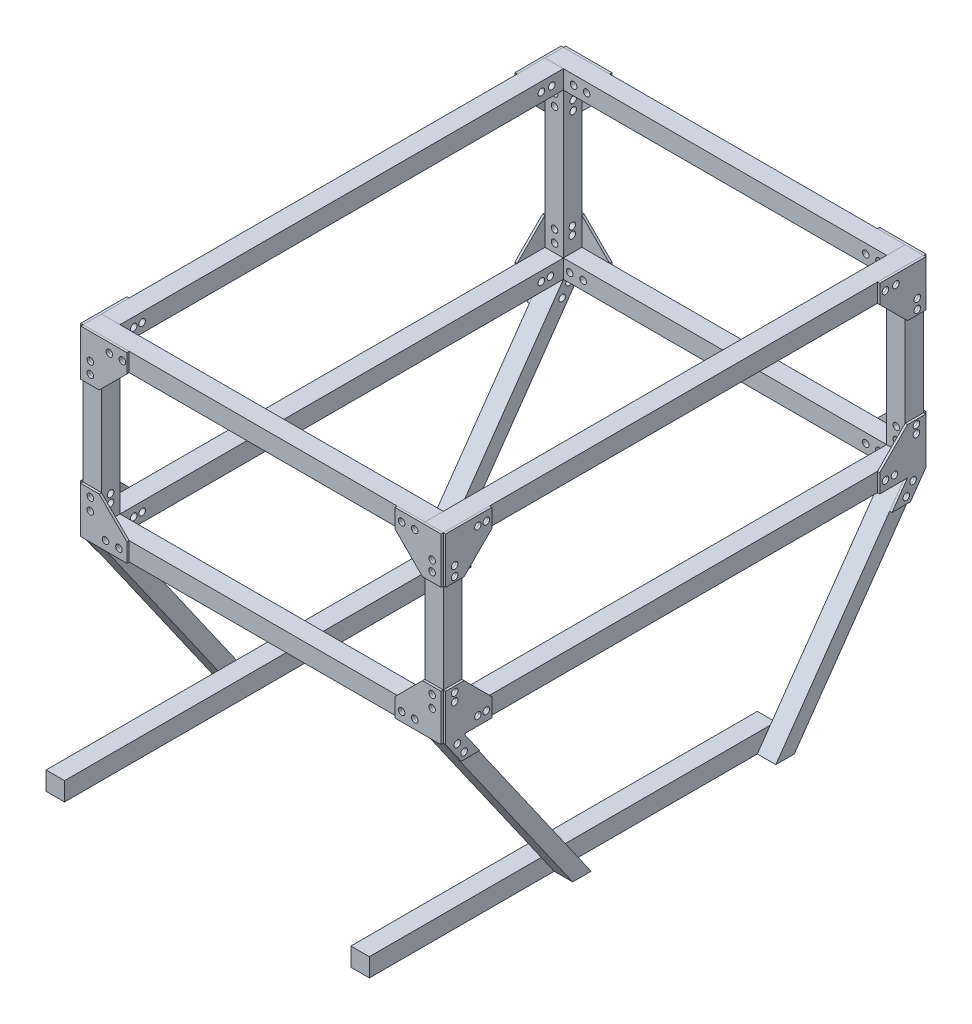
from build123d import *

# Parameters (mm, degrees)
SKETCH1_W                  = 12.7
SKETCH1_H                  = 12.7
BOSS_EXTRUDE1_DEPTH        = 304.8
SKETCH3_W                  = 12.7
SKETCH3_H                  = 12.7
BOSS_EXTRUDE2_DEPTH        = 222.25
BOSS_EXTRUDE2_DEPTH_BACK   = 12.7
BOSS_EXTRUDE2_2_DEPTH      = 222.25
BOSS_EXTRUDE2_2_DEPTH_BACK = 12.7
SKETCH5_W                  = 12.7
SKETCH5_H                  = 12.7
BOSS_EXTRUDE3_DEPTH        = 317.5
BOSS_EXTRUDE3_DEPTH_BACK   = 12.7
SKETCH6_W                  = 12.7
SKETCH6_H                  = 12.7
BOSS_EXTRUDE4_DEPTH        = 100
BOSS_EXTRUDE4_2_DEPTH      = 100
BOSS_EXTRUDE4_3_DEPTH      = 100
BOSS_EXTRUDE4_4_DEPTH      = 100
SKETCH8_W                  = 12.7
SKETCH8_H                  = 12.7
BOSS_EXTRUDE6_DEPTH        = 247.65
SKETCH9_W                  = 12.7
SKETCH9_H                  = 12.7
BOSS_EXTRUDE8_DEPTH        = 317.5
BOSS_EXTRUDE8_2_DEPTH      = 317.5
SKETCH10_W                 = 12.7
SKETCH10_H                 = 12.7
BOSS_EXTRUDE9_DEPTH        = 222.25
BOSS_EXTRUDE11_DEPTH       = 12.7
BOSS_EXTRUDE12_DEPTH       = 12.7
BOSS_EXTRUDE13_DEPTH       = 12.7
BOSS_EXTRUDE13_2_DEPTH     = 12.7
SKETCH15_W                 = 279.4
SKETCH15_H                 = 12.7
BOSS_EXTRUDE15_DEPTH       = 12.7
SKETCH16_W                 = 279.4
SKETCH16_H                 = 12.7
BOSS_EXTRUDE16_DEPTH       = 12.7
SKETCH17_R                 = 2.25
BOSS_EXTRUDE17_DEPTH       = 1.5875
BOSS_EXTRUDE17_2_DEPTH     = 1.5875
BOSS_EXTRUDE17_3_DEPTH     = 1.5875
BOSS_EXTRUDE17_4_DEPTH     = 1.5875
BOSS_EXTRUDE18_DEPTH       = 1.5875
BOSS_EXTRUDE18_2_DEPTH     = 1.5875
BOSS_EXTRUDE18_3_DEPTH     = 1.5875
BOSS_EXTRUDE18_4_DEPTH     = 1.5875
BOSS_EXTRUDE19_DEPTH       = 1.5875
BOSS_EXTRUDE19_2_DEPTH     = 1.5875
BOSS_EXTRUDE19_3_DEPTH     = 1.5875
BOSS_EXTRUDE19_4_DEPTH     = 1.5875
SKETCH20_R                 = 2.25
BOSS_EXTRUDE20_DEPTH       = 1.5875
BOSS_EXTRUDE20_2_DEPTH     = 1.5875
BOSS_EXTRUDE20_3_DEPTH     = 1.5875
BOSS_EXTRUDE20_4_DEPTH     = 1.5875
SKETCH17_4_R               = 2.25
CUT_EXTRUDE1_DEPTH         = 250.2375
SKETCH17_6_R               = 2.25
CUT_EXTRUDE4_DEPTH         = 250.2375
SKETCH17_7_R               = 2.25
CUT_EXTRUDE5_DEPTH         = 250.2375
SKETCH20_2_R               = 2.25
CUT_EXTRUDE6_DEPTH         = 369.326357353


with BuildPart() as part:
    # Sketch1 → Boss-Extrude1 (new body)
    with BuildSketch(Plane.XY):
        with Locations((6.35, 6.35)):
            Rectangle(SKETCH1_W, SKETCH1_H)
    extrude(amount=BOSS_EXTRUDE1_DEPTH)


with BuildPart() as body_2:
    # Sketch3 → Boss-Extrude2 (new body, two sides)
    with BuildSketch(Plane(origin=(12.7, 0, 0), x_dir=(0, 0, -1), z_dir=(1, 0, 0))) as boss_extrude2_sk:
        with Locations((6.35, 6.35)):
            Rectangle(SKETCH3_W, SKETCH3_H)
    extrude(amount=BOSS_EXTRUDE2_DEPTH)
    extrude(boss_extrude2_sk.sketch, amount=-BOSS_EXTRUDE2_DEPTH_BACK)


with BuildPart() as body_3:
    # Sketch3 → Boss-Extrude2 2 (new body, two sides)
    with BuildSketch(Plane(origin=(12.7, 0, 0), x_dir=(0, 0, -1), z_dir=(1, 0, 0))) as boss_extrude2_2_sk:
        with Locations((-311.15, 6.35)):
            Rectangle(SKETCH3_W, SKETCH3_H)
    extrude(amount=BOSS_EXTRUDE2_2_DEPTH)
    extrude(boss_extrude2_2_sk.sketch, amount=-BOSS_EXTRUDE2_2_DEPTH_BACK)


with BuildPart() as body_4:
    # Sketch5 → Boss-Extrude3 (new body, two sides)
    with BuildSketch(Plane(origin=(0, 0, 304.8), x_dir=(-1, 0, 0), z_dir=(0, 0, -1))) as boss_extrude3_sk:
        with Locations((-241.3, 6.35)):
            Rectangle(SKETCH5_W, SKETCH5_H)
    extrude(amount=BOSS_EXTRUDE3_DEPTH)
    extrude(boss_extrude3_sk.sketch, amount=-BOSS_EXTRUDE3_DEPTH_BACK)


with BuildPart() as body_5:
    # Sketch6 → Boss-Extrude4 (new body)
    with BuildSketch(Plane.XZ):
        with Locations((6.35, 311.15)):
            Rectangle(SKETCH6_W, SKETCH6_H)
    extrude(amount=BOSS_EXTRUDE4_DEPTH)


with BuildPart() as body_6:
    # Sketch6 → Boss-Extrude4 2 (new body)
    with BuildSketch(Plane.XZ):
        with Locations((241.3, 311.15)):
            Rectangle(SKETCH6_W, SKETCH6_H)
    extrude(amount=BOSS_EXTRUDE4_2_DEPTH)


with BuildPart() as body_7:
    # Sketch6 → Boss-Extrude4 3 (new body)
    with BuildSketch(Plane.XZ):
        with Locations((6.35, -6.35)):
            Rectangle(SKETCH6_W, SKETCH6_H)
    extrude(amount=BOSS_EXTRUDE4_3_DEPTH)


with BuildPart() as body_8:
    # Sketch6 → Boss-Extrude4 4 (new body)
    with BuildSketch(Plane.XZ):
        with Locations((241.3, -6.35)):
            Rectangle(SKETCH6_W, SKETCH6_H)
    extrude(amount=BOSS_EXTRUDE4_4_DEPTH)


with BuildPart() as body_9:
    # Sketch8 → Boss-Extrude6 (new body)
    with BuildSketch(Plane(origin=(247.65, 0, 0), x_dir=(0, 0, -1), z_dir=(1, 0, 0))):
        with Locations((-311.15, -106.35)):
            Rectangle(SKETCH8_W, SKETCH8_H)
    extrude(amount=-BOSS_EXTRUDE6_DEPTH)


with BuildPart() as body_10:
    # Sketch9 → Boss-Extrude8 (new body)
    with BuildSketch(Plane(origin=(0, 0, 304.8), x_dir=(-1, 0, 0), z_dir=(0, 0, -1))):
        with Locations((-241.3, -106.35)):
            Rectangle(SKETCH9_W, SKETCH9_H)
    extrude(amount=BOSS_EXTRUDE8_DEPTH)


with BuildPart() as body_11:
    # Sketch9 → Boss-Extrude8 2 (new body)
    with BuildSketch(Plane(origin=(0, 0, 304.8), x_dir=(-1, 0, 0), z_dir=(0, 0, -1))):
        with Locations((-6.35, -106.35)):
            Rectangle(SKETCH9_W, SKETCH9_H)
    extrude(amount=BOSS_EXTRUDE8_2_DEPTH)


with BuildPart() as body_12:
    # Sketch10 → Boss-Extrude9 (new body)
    with BuildSketch(Plane.ZY.offset(-234.95)):
        with Locations((-6.35, -106.35)):
            Rectangle(SKETCH10_W, SKETCH10_H)
    extrude(amount=BOSS_EXTRUDE9_DEPTH)


with BuildPart() as body_13:
    # Sketch12 → Boss-Extrude11 (new body)
    with BuildSketch(Plane.ZY):
        Polygon((-12.7, -112.7), (0, -112.7), (88.926357353, -239.7), (76.226357353, -239.7), align=None)
    extrude(amount=-BOSS_EXTRUDE11_DEPTH)


with BuildPart() as body_14:
    # Sketch13 → Boss-Extrude12 (new body)
    with BuildSketch(Plane.ZY):
        Polygon((317.5, -112.7), (304.8, -112.7), (215.873642647, -239.7), (228.573642647, -239.7), align=None)
    extrude(amount=-BOSS_EXTRUDE12_DEPTH)


with BuildPart() as body_15:
    # Sketch14 → Boss-Extrude13 (new body)
    with BuildSketch(Plane(origin=(247.65, 0, 0), x_dir=(0, 0, -1), z_dir=(1, 0, 0))):
        Polygon((-317.5, -112.7), (-228.573642647, -239.7), (-215.873642647, -239.7), (-304.8, -112.7), align=None)
    extrude(amount=-BOSS_EXTRUDE13_DEPTH)


with BuildPart() as body_16:
    # Sketch14 → Boss-Extrude13 2 (new body)
    with BuildSketch(Plane(origin=(247.65, 0, 0), x_dir=(0, 0, -1), z_dir=(1, 0, 0))):
        Polygon((-88.926357353, -239.7), (-76.226357353, -239.7), (12.7, -112.7), (0, -112.7), align=None)
    extrude(amount=-BOSS_EXTRUDE13_2_DEPTH)


with BuildPart() as body_17:
    # Sketch15 → Boss-Extrude15 (new body)
    with BuildSketch(Plane(origin=(12.7, 0, 0), x_dir=(0, 0, -1), z_dir=(1, 0, 0))):
        with Locations((-215.926357353, -233.35)):
            Rectangle(SKETCH15_W, SKETCH15_H)
    extrude(amount=BOSS_EXTRUDE15_DEPTH)


with BuildPart() as body_18:
    # Sketch16 → Boss-Extrude16 (new body)
    with BuildSketch(Plane.ZY.offset(-234.95)):
        with Locations((215.926357353, -233.35)):
            Rectangle(SKETCH16_W, SKETCH16_H)
    extrude(amount=BOSS_EXTRUDE16_DEPTH)


with BuildPart() as body_19:
    # Sketch17 → Boss-Extrude17 (new body)
    with BuildSketch(Plane.ZY):
        Polygon((-12.7, 12.7), (19.05, 12.7), (19.05, 0), (0, -19.05), (-12.7, -19.05), align=None)
        with Locations((-6.784745725, -15.720800994)):
            Circle(SKETCH17_R, mode=Mode.SUBTRACT)
        with Locations((-6.784745725, -9.184482746)):
            Circle(SKETCH17_R, mode=Mode.SUBTRACT)
        with Locations((15.120753266, 6.361355247)):
            Circle(SKETCH17_R, mode=Mode.SUBTRACT)
        with Locations((7.966134644, 6.361355247)):
            Circle(SKETCH17_R, mode=Mode.SUBTRACT)
    extrude(amount=BOSS_EXTRUDE17_DEPTH)


with BuildPart() as body_20:
    # Sketch17 → Boss-Extrude17 2 (new body)
    with BuildSketch(Plane.ZY):
        Polygon((317.5, 12.7), (285.75, 12.7), (285.75, 0), (304.8, -19.05), (317.5, -19.05), align=None)
        with Locations((289.5092956, 6.361355247)):
            Circle(SKETCH17_R, mode=Mode.SUBTRACT)
        with Locations((295.315666091, 6.361355247)):
            Circle(SKETCH17_R, mode=Mode.SUBTRACT)
        with Locations((311.256792347, -15.720800994)):
            Circle(SKETCH17_R, mode=Mode.SUBTRACT)
        with Locations((311.256792347, -9.184482746)):
            Circle(SKETCH17_R, mode=Mode.SUBTRACT)
    extrude(amount=BOSS_EXTRUDE17_2_DEPTH)


with BuildPart() as body_21:
    # Sketch17 → Boss-Extrude17 3 (new body)
    with BuildSketch(Plane.ZY):
        Polygon((-12.7, -112.7), (-12.7, -80.95), (0, -80.95), (19.05, -100), (19.05, -112.7), (0, -112.7), (10.671162882, -127.94), (-2.028837118, -127.94), align=None)
        with Locations((-3.838603571, -116.183590647)):
            Circle(SKETCH17_R, mode=Mode.SUBTRACT)
        with Locations((0.82993715, -123.403794366)):
            Circle(SKETCH17_R, mode=Mode.SUBTRACT)
        with Locations((-6.105589472, -84.025820636)):
            Circle(SKETCH17_R, mode=Mode.SUBTRACT)
        with Locations((-6.105589472, -89.426038711)):
            Circle(SKETCH17_R, mode=Mode.SUBTRACT)
        with Locations((15.120753266, -106.479113212)):
            Circle(SKETCH17_R, mode=Mode.SUBTRACT)
        with Locations((8.932434355, -106.479113212)):
            Circle(SKETCH17_R, mode=Mode.SUBTRACT)
    extrude(amount=BOSS_EXTRUDE17_3_DEPTH)


with BuildPart() as body_22:
    # Sketch17 → Boss-Extrude17 4 (new body)
    with BuildSketch(Plane.ZY):
        Polygon((317.5, -112.7), (317.5, -80.95), (304.8, -80.95), (285.75, -100), (285.75, -112.7), (304.8, -112.7), (294.128837118, -127.94), (306.828837118, -127.94), align=None)
        with Locations((311.256792347, -84.677899091)):
            Circle(SKETCH17_R, mode=Mode.SUBTRACT)
        with Locations((289.5092956, -106.479113212)):
            Circle(SKETCH17_R, mode=Mode.SUBTRACT)
        with Locations((295.315666091, -106.479113212)):
            Circle(SKETCH17_R, mode=Mode.SUBTRACT)
        with Locations((309.468904671, -116.183590647)):
            Circle(SKETCH17_R, mode=Mode.SUBTRACT)
        with Locations((304.8, -123.403794366)):
            Circle(SKETCH17_R, mode=Mode.SUBTRACT)
        with Locations((311.256792347, -90.324282695)):
            Circle(SKETCH17_R, mode=Mode.SUBTRACT)
    extrude(amount=BOSS_EXTRUDE17_4_DEPTH)


with BuildPart() as body_23:
    # Sketch18 → Boss-Extrude18 (new body)
    with BuildSketch(Plane.XY.offset(317.5)):
        Polygon((0, 12.7), (31.75, 12.7), (31.75, 0), (12.7, -19.05), (0, -19.05), align=None)
    extrude(amount=BOSS_EXTRUDE18_DEPTH)


with BuildPart() as body_24:
    # Sketch18 → Boss-Extrude18 2 (new body)
    with BuildSketch(Plane.XY.offset(317.5)):
        Polygon((247.65, 12.7), (247.65, -19.05), (234.95, -19.05), (215.9, 0), (215.9, 12.7), align=None)
    extrude(amount=BOSS_EXTRUDE18_2_DEPTH)


with BuildPart() as body_25:
    # Sketch18 → Boss-Extrude18 3 (new body)
    with BuildSketch(Plane.XY.offset(317.5)):
        Polygon((0, -112.7), (31.75, -112.7), (31.75, -100), (12.7, -80.95), (0, -80.95), align=None)
    extrude(amount=BOSS_EXTRUDE18_3_DEPTH)


with BuildPart() as body_26:
    # Sketch18 → Boss-Extrude18 4 (new body)
    with BuildSketch(Plane.XY.offset(317.5)):
        Polygon((247.65, -112.7), (247.65, -80.95), (234.95, -80.95), (215.9, -100), (215.9, -112.7), align=None)
    extrude(amount=BOSS_EXTRUDE18_4_DEPTH)


with BuildPart() as body_27:
    # Sketch19 → Boss-Extrude19 (new body)
    with BuildSketch(Plane(origin=(247.65, 0, 0), x_dir=(0, 0, -1), z_dir=(1, 0, 0))):
        Polygon((-317.5, 12.7), (-285.75, 12.7), (-285.75, 0), (-304.8, -19.05), (-317.5, -19.05), align=None)
    extrude(amount=BOSS_EXTRUDE19_DEPTH)


with BuildPart() as body_28:
    # Sketch19 → Boss-Extrude19 2 (new body)
    with BuildSketch(Plane(origin=(247.65, 0, 0), x_dir=(0, 0, -1), z_dir=(1, 0, 0))):
        Polygon((12.7, 12.7), (12.7, -19.05), (0, -19.05), (-19.05, 0), (-19.05, 12.7), align=None)
    extrude(amount=BOSS_EXTRUDE19_2_DEPTH)


with BuildPart() as body_29:
    # Sketch19 → Boss-Extrude19 3 (new body)
    with BuildSketch(Plane(origin=(247.65, 0, 0), x_dir=(0, 0, -1), z_dir=(1, 0, 0))):
        Polygon((-285.75, -112.7), (-285.75, -100), (-304.8, -80.95), (-317.5, -80.95), (-317.5, -112.7), (-306.828837118, -127.94), (-294.128837118, -127.94), (-304.8, -112.7), align=None)
    extrude(amount=BOSS_EXTRUDE19_3_DEPTH)


with BuildPart() as body_30:
    # Sketch19 → Boss-Extrude19 4 (new body)
    with BuildSketch(Plane(origin=(247.65, 0, 0), x_dir=(0, 0, -1), z_dir=(1, 0, 0))):
        Polygon((12.7, -112.7), (12.7, -80.95), (0, -80.95), (-19.05, -100), (-19.05, -112.7), (0, -112.7), (-10.671162882, -127.94), (2.028837118, -127.94), align=None)
    extrude(amount=BOSS_EXTRUDE19_4_DEPTH)


with BuildPart() as body_31:
    # Sketch20 → Boss-Extrude20 (new body)
    with BuildSketch(Plane(origin=(0, 0, -12.7), x_dir=(-1, 0, 0), z_dir=(0, 0, -1))):
        Polygon((-247.65, 12.7), (-215.9, 12.7), (-215.9, 0), (-234.95, -20.344786023), (-247.65, -19.05), align=None)
        with Locations((-220.629320264, 6.349721933)):
            Circle(SKETCH20_R, mode=Mode.SUBTRACT)
        with Locations((-229.622707283, 6.349721933)):
            Circle(SKETCH20_R, mode=Mode.SUBTRACT)
        with Locations((-241.543603879, -12.822038256)):
            Circle(SKETCH20_R, mode=Mode.SUBTRACT)
        with Locations((-241.543603879, -5.789410119)):
            Circle(SKETCH20_R, mode=Mode.SUBTRACT)
    extrude(amount=BOSS_EXTRUDE20_DEPTH)


with BuildPart() as body_32:
    # Sketch20 → Boss-Extrude20 2 (new body)
    with BuildSketch(Plane(origin=(0, 0, -12.7), x_dir=(-1, 0, 0), z_dir=(0, 0, -1))):
        Polygon((0, 12.7), (-31.75, 12.7), (-31.75, 0), (-12.7, -19.05), (0, -19.05), align=None)
        with Locations((-28.670930573, 6.349721933)):
            Circle(SKETCH20_R, mode=Mode.SUBTRACT)
        with Locations((-19.69681109, 6.349721933)):
            Circle(SKETCH20_R, mode=Mode.SUBTRACT)
        with Locations((-6.621386862, -4.890192644)):
            Circle(SKETCH20_R, mode=Mode.SUBTRACT)
        with Locations((-6.621386862, -12.822038256)):
            Circle(SKETCH20_R, mode=Mode.SUBTRACT)
    extrude(amount=BOSS_EXTRUDE20_2_DEPTH)


with BuildPart() as body_33:
    # Sketch20 → Boss-Extrude20 3 (new body)
    with BuildSketch(Plane(origin=(0, 0, -12.7), x_dir=(-1, 0, 0), z_dir=(0, 0, -1))):
        Polygon((-247.65, -112.7), (-215.9, -112.7), (-215.9, -100), (-234.95, -80.95), (-247.65, -80.95), align=None)
        with Locations((-241.543603879, -85.852301949)):
            Circle(SKETCH20_R, mode=Mode.SUBTRACT)
        with Locations((-241.543603879, -94.169193352)):
            Circle(SKETCH20_R, mode=Mode.SUBTRACT)
        with Locations((-229.622707283, -106.487386504)):
            Circle(SKETCH20_R, mode=Mode.SUBTRACT)
        with Locations((-220.629320264, -106.487386504)):
            Circle(SKETCH20_R, mode=Mode.SUBTRACT)
    extrude(amount=BOSS_EXTRUDE20_3_DEPTH)


with BuildPart() as body_34:
    # Sketch20 → Boss-Extrude20 4 (new body)
    with BuildSketch(Plane(origin=(0, 0, -12.7), x_dir=(-1, 0, 0), z_dir=(0, 0, -1))):
        Polygon((0, -112.7), (0, -80.95), (-12.7, -80.95), (-31.75, -100), (-31.75, -112.7), align=None)
        with Locations((-6.621386862, -85.852301949)):
            Circle(SKETCH20_R, mode=Mode.SUBTRACT)
        with Locations((-6.621386862, -94.169193352)):
            Circle(SKETCH20_R, mode=Mode.SUBTRACT)
        with Locations((-26.28770183, -106.487386504)):
            Circle(SKETCH20_R, mode=Mode.SUBTRACT)
        with Locations((-17.062185059, -106.487386504)):
            Circle(SKETCH20_R, mode=Mode.SUBTRACT)
    extrude(amount=BOSS_EXTRUDE20_4_DEPTH)


with BuildPart() as cut_extrude1_tool:
    # Sketch17_4 → Cut-Extrude1 (new body, through all)
    with BuildSketch(Plane.ZY):
        with Locations((15.120753266, 6.361355247)):
            Circle(SKETCH17_4_R)
        with Locations((7.966134644, 6.361355247)):
            Circle(SKETCH17_4_R)
        with Locations((-6.784745725, -9.184482746)):
            Circle(SKETCH17_4_R)
        with Locations((-6.784745725, -15.720800994)):
            Circle(SKETCH17_4_R)
    extrude(amount=-CUT_EXTRUDE1_DEPTH)


with BuildPart() as part_1:
    add(part.part)

    # Cut-Extrude1: cut by cut_extrude1_tool
    add(cut_extrude1_tool.part, mode=Mode.SUBTRACT)


with BuildPart() as body_4_1:
    add(body_4.part)

    # Cut-Extrude1: cut by cut_extrude1_tool
    add(cut_extrude1_tool.part, mode=Mode.SUBTRACT)


with BuildPart() as body_7_1:
    add(body_7.part)

    # Cut-Extrude1: cut by cut_extrude1_tool
    add(cut_extrude1_tool.part, mode=Mode.SUBTRACT)


with BuildPart() as body_8_1:
    add(body_8.part)

    # Cut-Extrude1: cut by cut_extrude1_tool
    add(cut_extrude1_tool.part, mode=Mode.SUBTRACT)


with BuildPart() as body_28_1:
    add(body_28.part)

    # Cut-Extrude1: cut by cut_extrude1_tool
    add(cut_extrude1_tool.part, mode=Mode.SUBTRACT)


with BuildPart() as cut_extrude4_tool:
    # Sketch17_6 → Cut-Extrude4 (new body, through all)
    with BuildSketch(Plane.ZY):
        with Locations((-6.105589472, -84.025820636)):
            Circle(SKETCH17_6_R)
        with Locations((-6.105589472, -89.426038711)):
            Circle(SKETCH17_6_R)
        with Locations((8.932434355, -106.479113212)):
            Circle(SKETCH17_6_R)
        with Locations((15.120753266, -106.479113212)):
            Circle(SKETCH17_6_R)
        with Locations((-3.838603571, -116.183590647)):
            Circle(SKETCH17_6_R)
        with Locations((0.82993715, -123.403794366)):
            Circle(SKETCH17_6_R)
    extrude(amount=-CUT_EXTRUDE4_DEPTH)


with BuildPart() as body_7_2:
    add(body_7_1.part)

    # Cut-Extrude4: cut by cut_extrude4_tool
    add(cut_extrude4_tool.part, mode=Mode.SUBTRACT)


with BuildPart() as body_8_2:
    add(body_8_1.part)

    # Cut-Extrude4: cut by cut_extrude4_tool
    add(cut_extrude4_tool.part, mode=Mode.SUBTRACT)


with BuildPart() as body_10_1:
    add(body_10.part)

    # Cut-Extrude4: cut by cut_extrude4_tool
    add(cut_extrude4_tool.part, mode=Mode.SUBTRACT)


with BuildPart() as body_11_1:
    add(body_11.part)

    # Cut-Extrude4: cut by cut_extrude4_tool
    add(cut_extrude4_tool.part, mode=Mode.SUBTRACT)


with BuildPart() as body_13_1:
    add(body_13.part)

    # Cut-Extrude4: cut by cut_extrude4_tool
    add(cut_extrude4_tool.part, mode=Mode.SUBTRACT)


with BuildPart() as body_16_1:
    add(body_16.part)

    # Cut-Extrude4: cut by cut_extrude4_tool
    add(cut_extrude4_tool.part, mode=Mode.SUBTRACT)


with BuildPart() as body_30_1:
    add(body_30.part)

    # Cut-Extrude4: cut by cut_extrude4_tool
    add(cut_extrude4_tool.part, mode=Mode.SUBTRACT)


with BuildPart() as cut_extrude5_tool:
    # Sketch17_7 → Cut-Extrude5 (new body, through all)
    with BuildSketch(Plane.ZY):
        with Locations((289.5092956, 6.361355247)):
            Circle(SKETCH17_7_R)
        with Locations((295.315666091, 6.361355247)):
            Circle(SKETCH17_7_R)
        with Locations((311.256792347, -9.184482746)):
            Circle(SKETCH17_7_R)
        with Locations((311.256792347, -15.720800994)):
            Circle(SKETCH17_7_R)
        with Locations((311.256792347, -84.677899091)):
            Circle(SKETCH17_7_R)
        with Locations((311.256792347, -90.324282695)):
            Circle(SKETCH17_7_R)
        with Locations((295.315666091, -106.479113212)):
            Circle(SKETCH17_7_R)
        with Locations((289.5092956, -106.479113212)):
            Circle(SKETCH17_7_R)
        with Locations((309.468904671, -116.183590647)):
            Circle(SKETCH17_7_R)
        with Locations((304.8, -123.403794366)):
            Circle(SKETCH17_7_R)
    extrude(amount=-CUT_EXTRUDE5_DEPTH)


with BuildPart() as part_2:
    add(part_1.part)

    # Cut-Extrude5: cut by cut_extrude5_tool
    add(cut_extrude5_tool.part, mode=Mode.SUBTRACT)


with BuildPart() as body_4_2:
    add(body_4_1.part)

    # Cut-Extrude5: cut by cut_extrude5_tool
    add(cut_extrude5_tool.part, mode=Mode.SUBTRACT)


with BuildPart() as body_5_1:
    add(body_5.part)

    # Cut-Extrude5: cut by cut_extrude5_tool
    add(cut_extrude5_tool.part, mode=Mode.SUBTRACT)


with BuildPart() as body_6_1:
    add(body_6.part)

    # Cut-Extrude5: cut by cut_extrude5_tool
    add(cut_extrude5_tool.part, mode=Mode.SUBTRACT)


with BuildPart() as body_10_2:
    add(body_10_1.part)

    # Cut-Extrude5: cut by cut_extrude5_tool
    add(cut_extrude5_tool.part, mode=Mode.SUBTRACT)


with BuildPart() as body_11_2:
    add(body_11_1.part)

    # Cut-Extrude5: cut by cut_extrude5_tool
    add(cut_extrude5_tool.part, mode=Mode.SUBTRACT)


with BuildPart() as body_14_1:
    add(body_14.part)

    # Cut-Extrude5: cut by cut_extrude5_tool
    add(cut_extrude5_tool.part, mode=Mode.SUBTRACT)


with BuildPart() as body_15_1:
    add(body_15.part)

    # Cut-Extrude5: cut by cut_extrude5_tool
    add(cut_extrude5_tool.part, mode=Mode.SUBTRACT)


with BuildPart() as body_27_1:
    add(body_27.part)

    # Cut-Extrude5: cut by cut_extrude5_tool
    add(cut_extrude5_tool.part, mode=Mode.SUBTRACT)


with BuildPart() as body_29_1:
    add(body_29.part)

    # Cut-Extrude5: cut by cut_extrude5_tool
    add(cut_extrude5_tool.part, mode=Mode.SUBTRACT)


with BuildPart() as cut_extrude6_tool:
    # Sketch20_2 → Cut-Extrude6 (new body, through all)
    with BuildSketch(Plane(origin=(0, 0, -12.7), x_dir=(-1, 0, 0), z_dir=(0, 0, -1))):
        with Locations((-229.622707283, 6.349721933)):
            Circle(SKETCH20_2_R)
        with Locations((-220.629320264, 6.349721933)):
            Circle(SKETCH20_2_R)
        with Locations((-241.543603879, -5.789410119)):
            Circle(SKETCH20_2_R)
        with Locations((-241.543603879, -12.822038256)):
            Circle(SKETCH20_2_R)
        with Locations((-241.543603879, -85.852301949)):
            Circle(SKETCH20_2_R)
        with Locations((-241.543603879, -94.169193352)):
            Circle(SKETCH20_2_R)
        with Locations((-229.622707283, -106.487386504)):
            Circle(SKETCH20_2_R)
        with Locations((-220.629320264, -106.487386504)):
            Circle(SKETCH20_2_R)
        with Locations((-28.670930573, 6.349721933)):
            Circle(SKETCH20_2_R)
        with Locations((-19.69681109, 6.349721933)):
            Circle(SKETCH20_2_R)
        with Locations((-6.621386862, -4.890192644)):
            Circle(SKETCH20_2_R)
        with Locations((-6.621386862, -12.822038256)):
            Circle(SKETCH20_2_R)
        with Locations((-6.621386862, -85.852301949)):
            Circle(SKETCH20_2_R)
        with Locations((-6.621386862, -94.169193352)):
            Circle(SKETCH20_2_R)
        with Locations((-17.062185059, -106.487386504)):
            Circle(SKETCH20_2_R)
        with Locations((-26.28770183, -106.487386504)):
            Circle(SKETCH20_2_R)
    extrude(amount=-CUT_EXTRUDE6_DEPTH)


with BuildPart() as body_2_1:
    add(body_2.part)

    # Cut-Extrude6: cut by cut_extrude6_tool
    add(cut_extrude6_tool.part, mode=Mode.SUBTRACT)


with BuildPart() as body_3_1:
    add(body_3.part)

    # Cut-Extrude6: cut by cut_extrude6_tool
    add(cut_extrude6_tool.part, mode=Mode.SUBTRACT)


with BuildPart() as body_5_2:
    add(body_5_1.part)

    # Cut-Extrude6: cut by cut_extrude6_tool
    add(cut_extrude6_tool.part, mode=Mode.SUBTRACT)


with BuildPart() as body_6_2:
    add(body_6_1.part)

    # Cut-Extrude6: cut by cut_extrude6_tool
    add(cut_extrude6_tool.part, mode=Mode.SUBTRACT)


with BuildPart() as body_7_3:
    add(body_7_2.part)

    # Cut-Extrude6: cut by cut_extrude6_tool
    add(cut_extrude6_tool.part, mode=Mode.SUBTRACT)


with BuildPart() as body_8_3:
    add(body_8_2.part)

    # Cut-Extrude6: cut by cut_extrude6_tool
    add(cut_extrude6_tool.part, mode=Mode.SUBTRACT)


with BuildPart() as body_9_1:
    add(body_9.part)

    # Cut-Extrude6: cut by cut_extrude6_tool
    add(cut_extrude6_tool.part, mode=Mode.SUBTRACT)


with BuildPart() as body_12_1:
    add(body_12.part)

    # Cut-Extrude6: cut by cut_extrude6_tool
    add(cut_extrude6_tool.part, mode=Mode.SUBTRACT)


with BuildPart() as body_23_1:
    add(body_23.part)

    # Cut-Extrude6: cut by cut_extrude6_tool
    add(cut_extrude6_tool.part, mode=Mode.SUBTRACT)


with BuildPart() as body_24_1:
    add(body_24.part)

    # Cut-Extrude6: cut by cut_extrude6_tool
    add(cut_extrude6_tool.part, mode=Mode.SUBTRACT)


with BuildPart() as body_25_1:
    add(body_25.part)

    # Cut-Extrude6: cut by cut_extrude6_tool
    add(cut_extrude6_tool.part, mode=Mode.SUBTRACT)


with BuildPart() as body_26_1:
    add(body_26.part)

    # Cut-Extrude6: cut by cut_extrude6_tool
    add(cut_extrude6_tool.part, mode=Mode.SUBTRACT)


solid = Compound([body_17.part, body_18.part, body_19.part, body_20.part, body_21.part, body_22.part, body_31.part, body_32.part, body_33.part, body_34.part, body_28_1.part, body_13_1.part, body_16_1.part, body_30_1.part, part_2.part, body_4_2.part, body_10_2.part, body_11_2.part, body_14_1.part, body_15_1.part, body_27_1.part, body_29_1.part, body_2_1.part, body_3_1.part, body_5_2.part, body_6_2.part, body_7_3.part, body_8_3.part, body_9_1.part, body_12_1.part, body_23_1.part, body_24_1.part, body_25_1.part, body_26_1.part])
